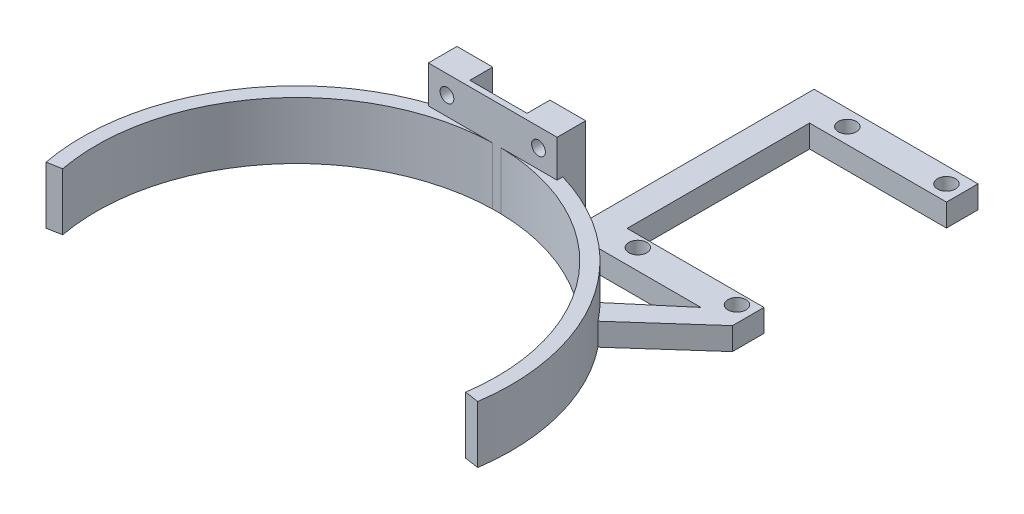
from build123d import *

# Parameters (mm, degrees)
BOSS_EXTRUDE1_DEPTH = 12.7
SKETCH2_W           = 28.575
SKETCH2_H           = 20.955
BOSS_EXTRUDE2_DEPTH = 6.35
SKETCH2_2_W         = 28.575
SKETCH2_2_H         = 20.955
BOSS_EXTRUDE3_DEPTH = 5.08
SKETCH3_W           = 12.7
SKETCH3_H           = 6.35
CUT_EXTRUDE1_DEPTH  = 5.08
SKETCH4_R           = 1.524
CUT_EXTRUDE2_DEPTH  = 6.35
SKETCH6_R           = 2
BOSS_EXTRUDE4_DEPTH = 5


with BuildPart() as part:
    # Sketch1 → Boss-Extrude1 (new body)
    with BuildSketch(Plane(origin=(0, 0, 0), x_dir=(1, 0, 0), z_dir=(0, 1, 0))):
        with BuildLine():
            Line((-45.903249768, -53.250574222), (-42.783043149, -52.66326199))
            ThreePointArc((-42.783043149, -52.66326199), (0, 0), (44.879778188, -50.888244756))
            Line((44.879778188, -50.888244756), (48.021201665, -51.348770042))
            ThreePointArc((48.021201665, -51.348770042), (-0.064274965, 3.174349339), (-45.903249768, -53.250574222))
        make_face()
    extrude(amount=BOSS_EXTRUDE1_DEPTH)

    # Sketch2 → Boss-Extrude2 (add)
    with BuildSketch(Plane.XY):
        with Locations((0, 10.4775)):
            Rectangle(SKETCH2_W, SKETCH2_H)
    extrude(amount=-BOSS_EXTRUDE2_DEPTH)

    # Sketch2_2 → Boss-Extrude3 (add)
    with BuildSketch(Plane.XY):
        with Locations((0, 10.4775)):
            Rectangle(SKETCH2_2_W, SKETCH2_2_H)
    extrude(amount=-BOSS_EXTRUDE3_DEPTH)

    # Sketch3 → Cut-Extrude1 (cut)
    with BuildSketch(Plane(origin=(0, 0, -6.35), x_dir=(-1, 0, 0), z_dir=(0, 0, -1))):
        with Locations((0, 17.78)):
            Rectangle(SKETCH3_W, SKETCH3_H)
    extrude(amount=-CUT_EXTRUDE1_DEPTH, mode=Mode.SUBTRACT)

    # Sketch4 → Cut-Extrude2 (cut)
    with BuildSketch(Plane(origin=(0, 0, -6.35), x_dir=(-1, 0, 0), z_dir=(0, 0, -1))):
        with Locations((-10.16, 4.1275)):
            Circle(SKETCH4_R)
        with Locations((-10.16, 16.8275)):
            Circle(SKETCH4_R)
        with Locations((10.16, 4.1275)):
            Circle(SKETCH4_R)
        with Locations((10.16, 16.8275)):
            Circle(SKETCH4_R)
    extrude(amount=-CUT_EXTRUDE2_DEPTH, mode=Mode.SUBTRACT)

    # Sketch6 → Boss-Extrude4 (add)
    with BuildSketch(Plane(origin=(0, 0, 0), x_dir=(1, 0, 0), z_dir=(0, 1, 0))):
        Polygon((38.224238065, -14.85997386), (54, -0.791157312), (54, 6.208842688), (23.618693952, 6.208842688), (23.618693952, 46.708842688), (54, 46.708842688), (54, 53.708842688), (17.618693952, 53.708842688), (17.618693952, 46.708842688), (17.618693952, 6.208842688), (17.618693952, -0.791157312), (17.618693952, -2.892477036), (23.618693952, -2.892477036), (23.618693952, -0.791157312), (47, -0.791157312), (34.870951122, -11.062681088), align=None)
        with Locations((28.5, 3.708842688)):
            Circle(SKETCH6_R, mode=Mode.SUBTRACT)
        with Locations((50.5, 3.708842688)):
            Circle(SKETCH6_R, mode=Mode.SUBTRACT)
        with Locations((28.5, 50.208842688)):
            Circle(SKETCH6_R, mode=Mode.SUBTRACT)
        with Locations((50.5, 50.208842688)):
            Circle(SKETCH6_R, mode=Mode.SUBTRACT)
    extrude(amount=BOSS_EXTRUDE4_DEPTH)


solid = part.part
